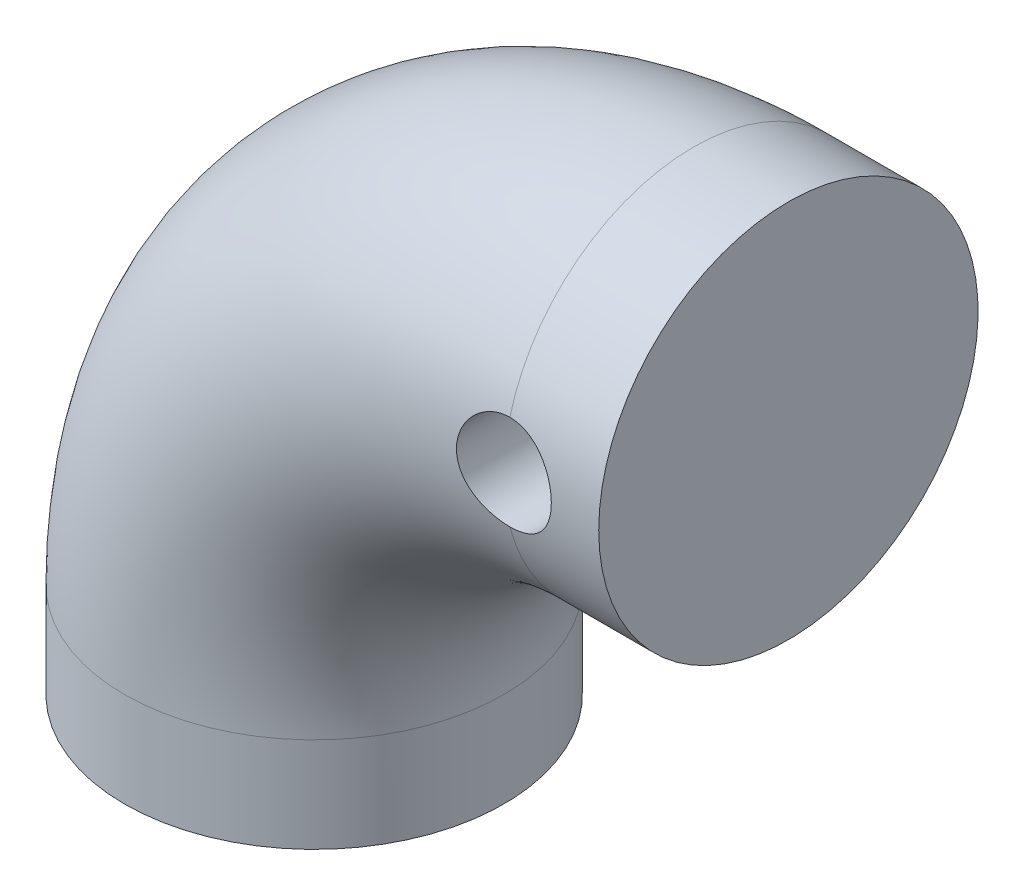
from build123d import *

# Parameters (mm, degrees)
SWEEP_2_PROFILE_R        = 8
CUT_EXTRUDE_3_DEPTH      = 10
CUT_EXTRUDE_3_DEPTH_BACK = 10
SKETCH_19_R              = 2


with BuildPart() as part:
    # 扫描2: sweep along a path in 草图1
    with BuildLine(Plane.XY) as sweep_2_path:
        Line((-32.264627437, -7.100709513), (-32.264627437, -3.100709513))
        ThreePointArc((-32.264627437, -3.100709513), (-27.578335936, 8.212998986), (-16.264627437, 12.899290487))
        Line((-16.264627437, 12.899290487), (-12.264627437, 12.899290487))
    # 扫描2 profile (on start of the path) → 扫描2 (sweep)
    with BuildSketch(Plane(origin=(-32.264627437, -7.100709513, 0), x_dir=(0, 0, 1), z_dir=(0, 1, 0))):
        Circle(SWEEP_2_PROFILE_R)
    sweep(path=sweep_2_path.line)

    # 草图19 → 切除-拉伸3 (cut, two sides: drawn at the far end of the back side and taken through both)
    with BuildSketch(Plane.XY.offset(-CUT_EXTRUDE_3_DEPTH_BACK)):
        with Locations((-16.264627437, 12.899290487)):
            Circle(SKETCH_19_R)
    extrude(amount=CUT_EXTRUDE_3_DEPTH + CUT_EXTRUDE_3_DEPTH_BACK, mode=Mode.SUBTRACT)


solid = part.part
